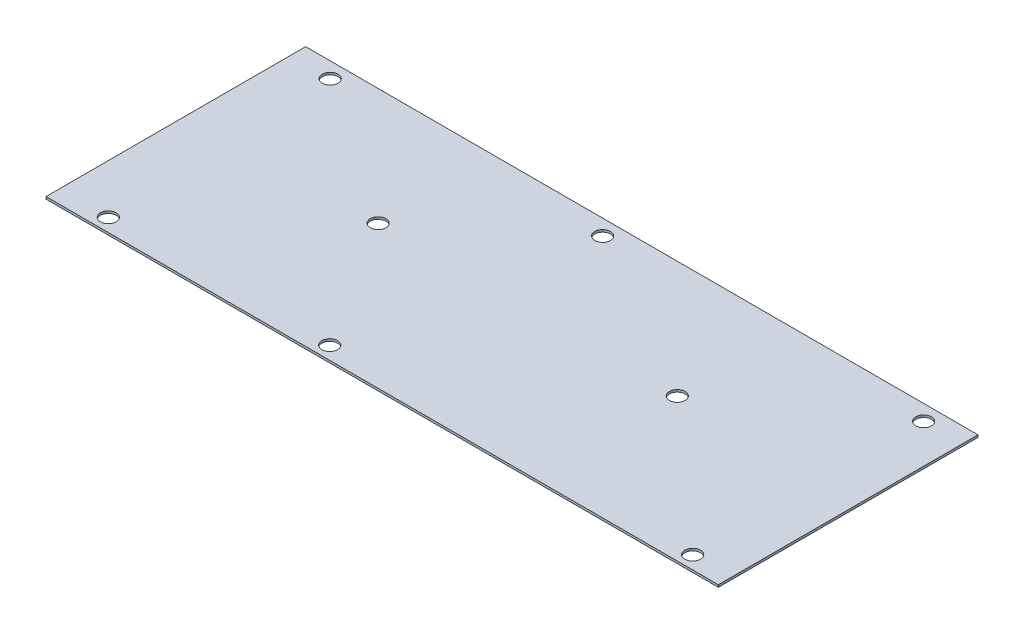
from build123d import *

# Parameters (mm, degrees)
CROQUIS1_W              = 300.0502
CROQUIS1_H              = 115.8748
CROQUIS1_R              = 3.5052
SALIENTE_EXTRUIR1_DEPTH = 1.016


with BuildPart() as part:
    # Croquis1 → Saliente-Extruir1 (new body)
    with BuildSketch(Plane(origin=(0, 0, 0), x_dir=(1, 0, 0), z_dir=(0, 1, 0))):
        Rectangle(CROQUIS1_W, CROQUIS1_H)
        with Locations((-128.1049, -52.0446)):
            Circle(CROQUIS1_R, mode=Mode.SUBTRACT)
        with Locations((-132.1689, 51.0286)):
            Circle(CROQUIS1_R, mode=Mode.SUBTRACT)
        with Locations((-10.5791, 51.0286)):
            Circle(CROQUIS1_R, mode=Mode.SUBTRACT)
        with Locations((132.6769, 51.0286)):
            Circle(CROQUIS1_R, mode=Mode.SUBTRACT)
        with Locations((132.6769, -52.0446)):
            Circle(CROQUIS1_R, mode=Mode.SUBTRACT)
        with Locations((-29.2989, -52.0446)):
            Circle(CROQUIS1_R, mode=Mode.SUBTRACT)
        with Locations((67.9069, 5.8674)):
            Circle(CROQUIS1_R, mode=Mode.SUBTRACT)
        with Locations((-65.6209, 5.8674)):
            Circle(CROQUIS1_R, mode=Mode.SUBTRACT)
    extrude(amount=SALIENTE_EXTRUIR1_DEPTH)


solid = part.part
